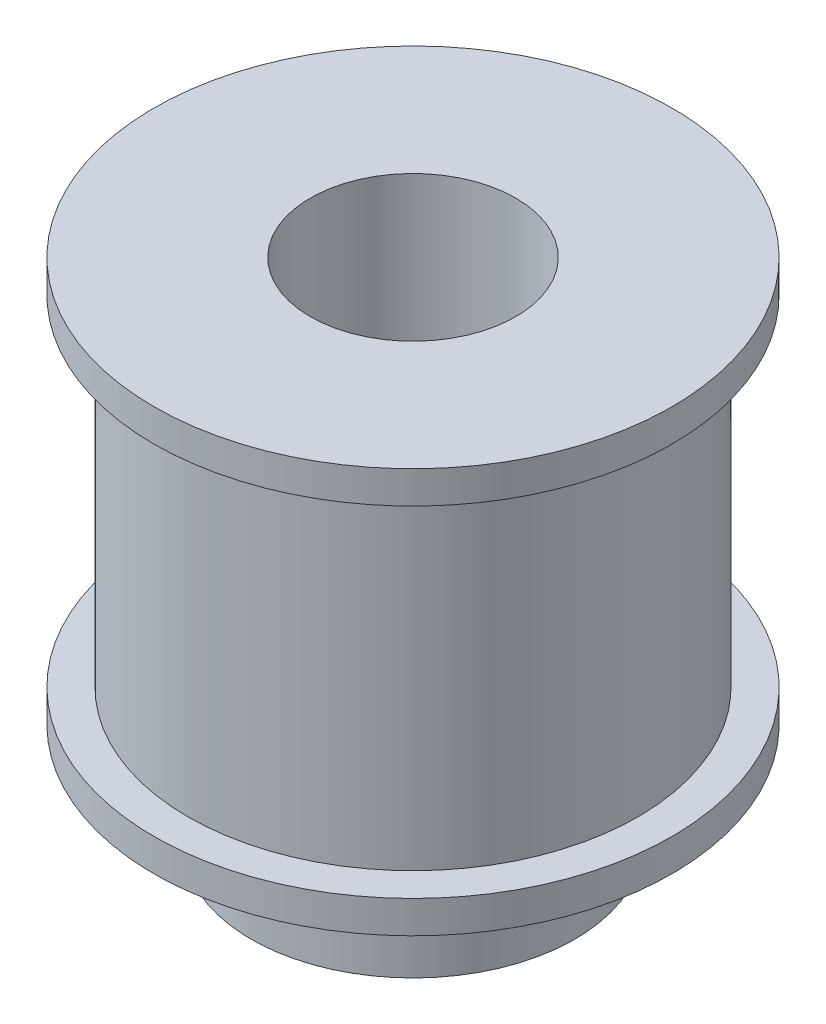
from build123d import *

# Parameters (mm, degrees)
SKETCH1_R               = 13.9
BOSS_EXTRUDE1_DEPTH     = 21
SKETCH2_R               = 16
BOSS_EXTRUDE2_DEPTH     = 2
SKETCH3_R               = 16
BOSS_EXTRUDE3_DEPTH     = 2
SKETCH5_R               = 10
SKETCH5_R_2             = 3
BOSS_EXTRUDE4_DEPTH     = 6.5
SKETCH4_R               = 6.35
CUT_EXTRUDE1_DEPTH      = 10
CUT_EXTRUDE1_DEPTH_BACK = 26


with BuildPart() as part:
    # Sketch1 → Boss-Extrude1 (new body)
    with BuildSketch(Plane(origin=(0, 0, 0), x_dir=(1, 0, 0), z_dir=(0, 1, 0))):
        Circle(SKETCH1_R)
    extrude(amount=BOSS_EXTRUDE1_DEPTH)

    # Sketch2 → Boss-Extrude2 (add)
    with BuildSketch(Plane(origin=(0, 21, 0), x_dir=(1, 0, 0), z_dir=(0, 1, 0))):
        Circle(SKETCH2_R)
    extrude(amount=BOSS_EXTRUDE2_DEPTH)

    # Sketch3 → Boss-Extrude3 (add)
    with BuildSketch(Plane.XZ):
        Circle(SKETCH3_R)
    extrude(amount=BOSS_EXTRUDE3_DEPTH)

    # Sketch5 → Boss-Extrude4 (add)
    with BuildSketch(Plane.XZ.offset(2)):
        Circle(SKETCH5_R)
        Circle(SKETCH5_R_2, mode=Mode.SUBTRACT)
    extrude(amount=BOSS_EXTRUDE4_DEPTH)

    # Sketch4 → Cut-Extrude1 (cut, two sides)
    with BuildSketch(Plane.XZ.offset(2)) as cut_extrude1_sk:
        Circle(SKETCH4_R)
    extrude(amount=CUT_EXTRUDE1_DEPTH, mode=Mode.SUBTRACT)
    extrude(cut_extrude1_sk.sketch, amount=-CUT_EXTRUDE1_DEPTH_BACK, mode=Mode.SUBTRACT)


solid = part.part
